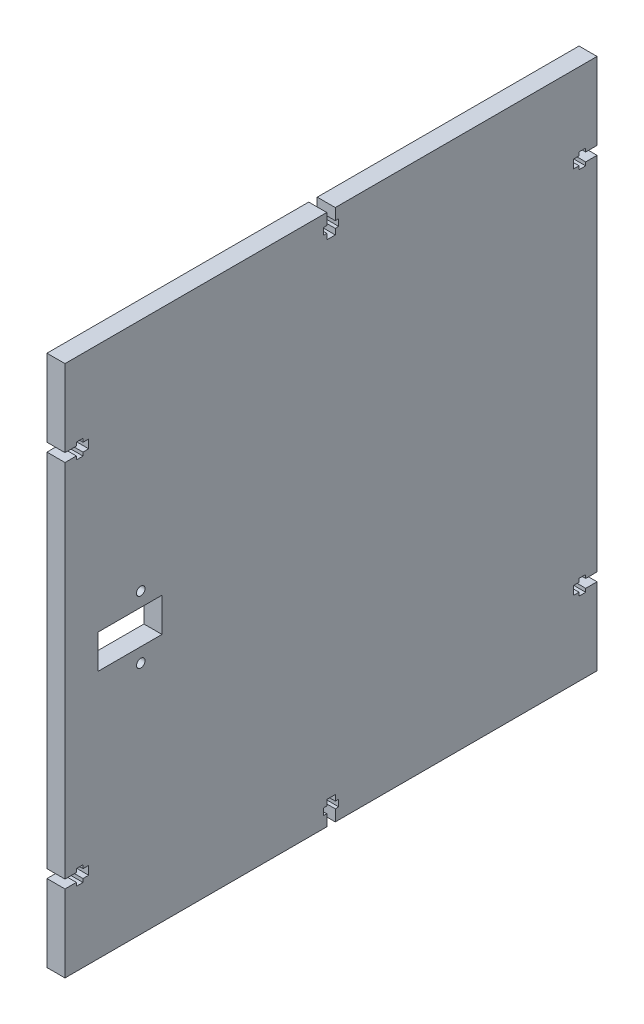
from build123d import *

# Parameters (mm, degrees)
SKETCH1_W           = 187.3
SKETCH1_H           = 187.3
BOSS_EXTRUDE1_DEPTH = 6.35
SKETCH2_W           = 22.55
SKETCH2_H           = 11.95
CUT_EXTRUDE1_DEPTH  = 6.35
SKETCH3_R           = 1.5
CUT_EXTRUDE2_DEPTH  = 7.35
CUT_EXTRUDE3_DEPTH  = 7.35


with BuildPart() as part:
    # Sketch1 → Boss-Extrude1 (new body)
    with BuildSketch(Plane(origin=(0, 0, 0), x_dir=(0, 0, -1), z_dir=(1, 0, 0))):
        Rectangle(SKETCH1_W, SKETCH1_H)
    extrude(amount=BOSS_EXTRUDE1_DEPTH)

    # Sketch2 → Cut-Extrude1 (cut)
    with BuildSketch(Plane(origin=(6.35, 0, 0), x_dir=(0, 0, -1), z_dir=(1, 0, 0))):
        with Locations((-70.783988916, 0)):
            Rectangle(SKETCH2_W, SKETCH2_H)
    extrude(amount=-CUT_EXTRUDE1_DEPTH, mode=Mode.SUBTRACT)

    # Sketch3 → Cut-Extrude2 (cut, through all)
    with BuildSketch(Plane(origin=(6.35, 0, 0), x_dir=(0, 0, -1), z_dir=(1, 0, 0))):
        with Locations((-66.978988916, 11)):
            Circle(SKETCH3_R)
        with Locations((-66.978988916, -11)):
            Circle(SKETCH3_R)
    extrude(amount=-CUT_EXTRUDE2_DEPTH, mode=Mode.SUBTRACT)

    # Sketch4 → Cut-Extrude3 (cut, through all)
    with BuildSketch(Plane(origin=(6.35, 0, 0), x_dir=(0, 0, -1), z_dir=(1, 0, 0))):
        Polygon((-93.65, 66.5), (-89.65, 66.5), (-89.65, 67.71), (-87.3, 67.71), (-87.3, 66.5), (-85.3, 66.5), (-85.3, 63.5), (-87.3, 63.5), (-87.3, 62.29), (-89.65, 62.29), (-89.65, 63.5), (-93.65, 63.5), align=None)
        Polygon((-87.3, -63.5), (-87.3, -62.29), (-89.65, -62.29), (-89.65, -63.5), (-93.65, -63.5), (-93.65, -66.5), (-89.65, -66.5), (-89.65, -67.71), (-87.3, -67.71), (-87.3, -66.5), (-85.3, -66.5), (-85.3, -63.5), align=None)
        Polygon((93.65, -66.5), (89.65, -66.5), (89.65, -67.71), (87.3, -67.71), (87.3, -66.5), (85.3, -66.5), (85.3, -63.5), (87.3, -63.5), (87.3, -62.29), (89.65, -62.29), (89.65, -63.5), (93.65, -63.5), align=None)
        Polygon((87.3, 63.5), (87.3, 62.29), (89.65, 62.29), (89.65, 63.5), (93.65, 63.5), (93.65, 66.5), (89.65, 66.5), (89.65, 67.71), (87.3, 67.71), (87.3, 66.5), (85.3, 66.5), (85.3, 63.5), align=None)
        Polygon((-1.5, 93.65), (-1.5, 89.65), (-2.71, 89.65), (-2.71, 87.3), (-1.5, 87.3), (-1.5, 85.3), (1.5, 85.3), (1.5, 87.3), (2.71, 87.3), (2.71, 89.65), (1.5, 89.65), (1.5, 93.65), align=None)
        Polygon((-2.71, -87.3), (-1.5, -87.3), (-1.5, -85.3), (1.5, -85.3), (1.5, -87.3), (2.71, -87.3), (2.71, -89.65), (1.5, -89.65), (1.5, -93.65), (-1.5, -93.65), (-1.5, -89.65), (-2.71, -89.65), align=None)
    extrude(amount=-CUT_EXTRUDE3_DEPTH, mode=Mode.SUBTRACT)


solid = part.part
